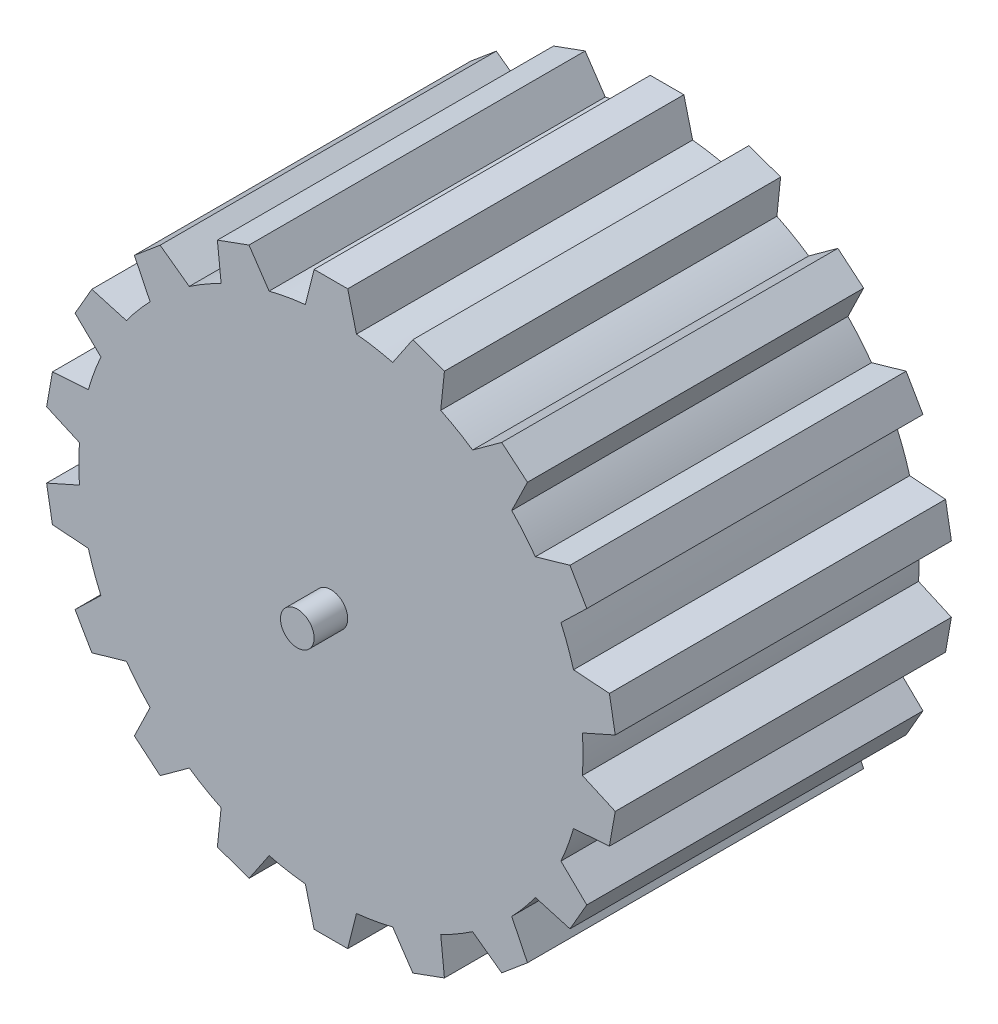
from build123d import *

# Parameters (mm, degrees)
SKETCH1_R           = 15
BOSS_EXTRUDE1_DEPTH = 20
BOSS_EXTRUDE2_DEPTH = 20
CIRPATTERN1_COUNT   = 18
SKETCH3_R           = 1
BOSS_EXTRUDE3_DEPTH = 2
SKETCH4_R           = 1
BOSS_EXTRUDE4_DEPTH = 2


with BuildPart() as part:
    # Sketch1 → Boss-Extrude1 (new body)
    with BuildSketch(Plane.XY):
        Circle(SKETCH1_R)
    extrude(amount=BOSS_EXTRUDE1_DEPTH)

    # Sketch2 → Boss-Extrude2 (add)
    with BuildSketch(Plane.XY.offset(20)):
        Polygon((0, 17), (1, 17), (2, 13), (0, 13), (-2, 13), (-1, 17), align=None)
    boss_extrude2 = extrude(amount=-BOSS_EXTRUDE2_DEPTH)

    # CirPattern1: Boss-Extrude2 ×18 about axis
    cirpattern1_axis = Axis((0, 0, 0), (0, 0, 1))
    for i in range(1, CIRPATTERN1_COUNT):
        add(boss_extrude2.rotate(cirpattern1_axis, i * 360 / CIRPATTERN1_COUNT))

    # Sketch3 → Boss-Extrude3 (add)
    with BuildSketch(Plane(origin=(0, 0, 0), x_dir=(-1, 0, 0), z_dir=(0, 0, -1))):
        Circle(SKETCH3_R)
    extrude(amount=BOSS_EXTRUDE3_DEPTH)

    # Sketch4 → Boss-Extrude4 (add)
    with BuildSketch(Plane.XY.offset(20)):
        Circle(SKETCH4_R)
    extrude(amount=BOSS_EXTRUDE4_DEPTH)


solid = part.part
